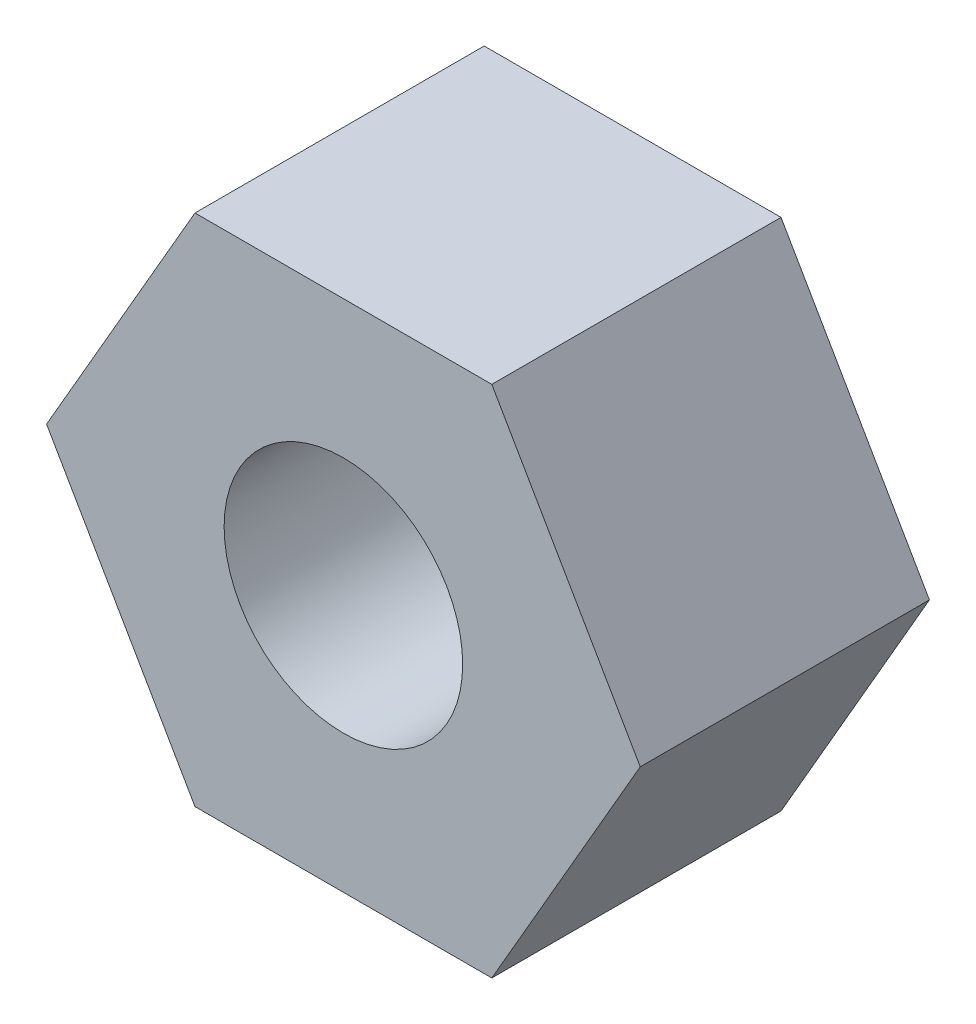
from build123d import *

# Parameters (mm, degrees)
SKETCH1_R      = 1.4732
EXTRUDE1_DEPTH = 3.571875


with BuildPart() as part:
    # Sketch1 → Extrude1 (new body)
    with BuildSketch(Plane.XY):
        Polygon((3.666174209, 0), (1.833087105, 3.175), (-1.833087105, 3.175), (-3.666174209, 0), (-1.833087105, -3.175), (1.833087105, -3.175), align=None)
        Circle(SKETCH1_R, mode=Mode.SUBTRACT)
    extrude(amount=EXTRUDE1_DEPTH)


solid = part.part
